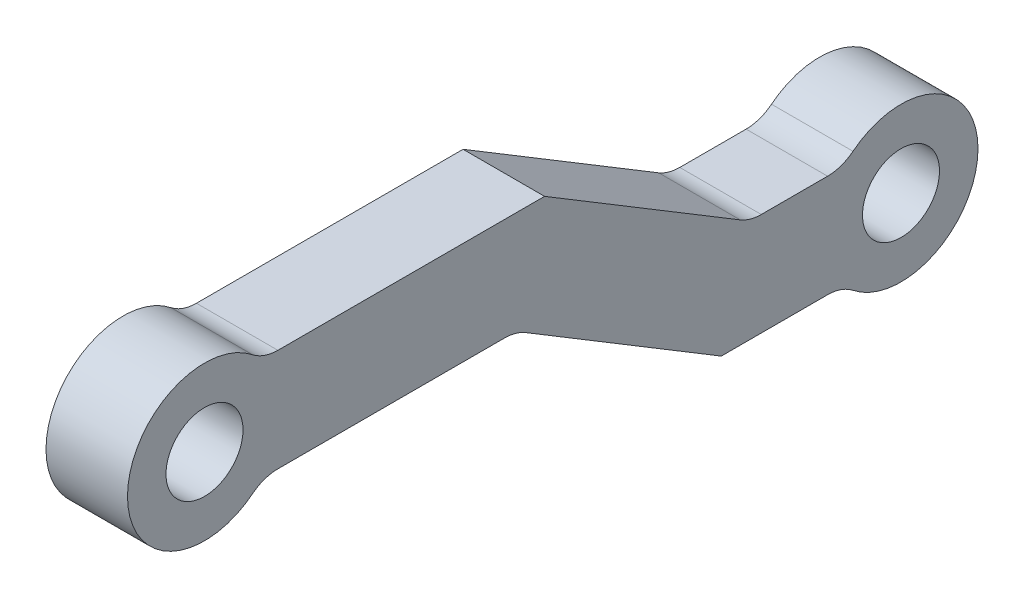
from build123d import *

# Parameters (mm, degrees)
SKETCH2_R           = 1.5
BOSS_EXTRUDE1_DEPTH = 3.175
FILLET1_R           = 1.5875


with BuildPart() as part:
    # Sketch2 → Boss-Extrude1 (new body)
    with BuildSketch(Plane(origin=(0, 0, 0), x_dir=(0, 0, -1), z_dir=(1, 0, 0))):
        with BuildLine():
            Line((13.247387042, 2), (2.236067977, 2))
            ThreePointArc((2.236067977, 2), (-3, 0), (2.236067977, -2))
            Line((2.236067977, -2), (12.13290764, -2))
            Line((12.13290764, -2), (20.13290764, -6.833106971))
            Line((20.13290764, -6.833106971), (24.896839663, -6.833106971))
            ThreePointArc((24.896839663, -6.833106971), (30.13290764, -4.833106971), (24.896839663, -2.833106971))
            Line((24.896839663, -2.833106971), (21.247387042, -2.833106971))
            Line((21.247387042, -2.833106971), (13.247387042, 2))
        make_face()
        Circle(SKETCH2_R, mode=Mode.SUBTRACT)
        with Locations((27.13290764, -4.833106971)):
            Circle(SKETCH2_R, mode=Mode.SUBTRACT)
    extrude(amount=BOSS_EXTRUDE1_DEPTH)

    # Fillet1
    fillet1_edges = [part.edges().sort_by_distance(p)[0] for p in [
        (1.5875, -6.833106971, -24.896839663),
        (1.5875, -2, -12.13290764),
        (1.5875, -2, -2.236067977),
        (1.5875, 2, -2.236067977),
        (1.5875, -2.833106971, -21.247387042),
        (1.5875, -2.833106971, -24.896839663),
    ]]
    fillet(fillet1_edges, radius=FILLET1_R)


solid = part.part
